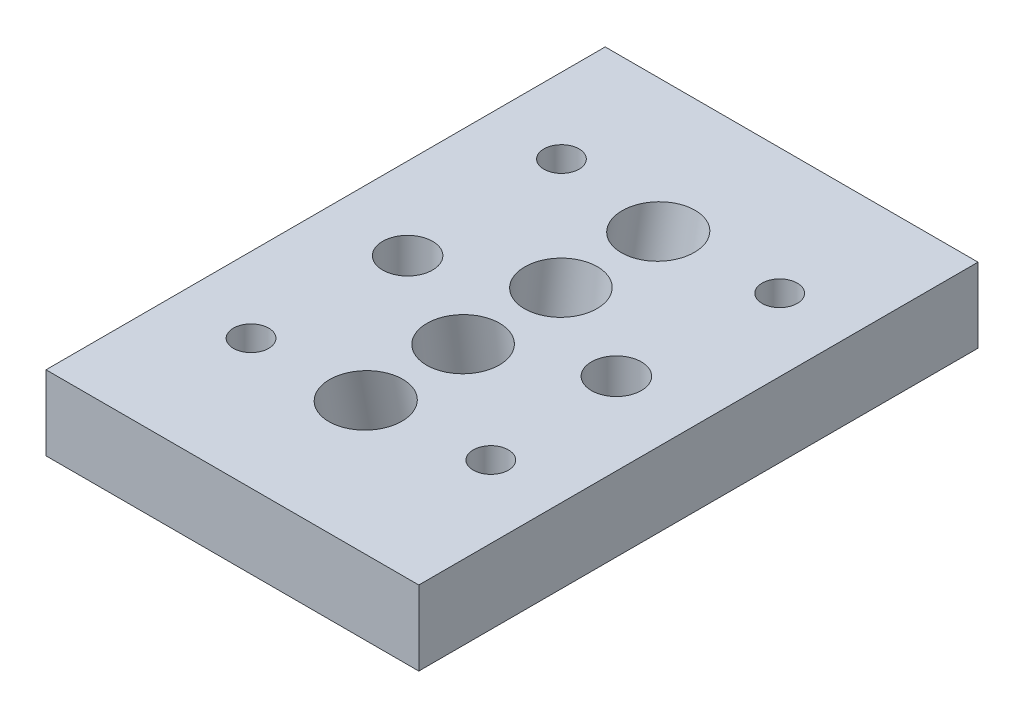
from build123d import *

# Parameters (mm, degrees)
SKETCH2_W                = 25.4
SKETCH2_H                = 38.1
BOSS_EXTRUDE1_DEPTH      = 5.08
CUT_EXTRUDE1_START       = -2.790735945
SKETCH7_R                = 2.4638
CUT_EXTRUDE1_DEPTH       = 11.685356434
CUT_EXTRUDE2_START       = -12.037410464
SKETCH16_R               = 2.4638
CUT_EXTRUDE2_DEPTH       = 14.163842911
M3_CLEARANCE_HOLE1_D     = 3.4
M3_CLEARANCE_HOLE1_DEPTH = 25.4
M3_CLEARANCE_HOLE1_TIP   = 1.021463052
M2_CLEARANCE_HOLE1_D     = 2.4
M2_CLEARANCE_HOLE1_DEPTH = 25.4
M2_CLEARANCE_HOLE1_TIP   = 0.721032743
M2_CLEARANCE_HOLE2_D     = 2.4
M2_CLEARANCE_HOLE2_DEPTH = 25.4
M2_CLEARANCE_HOLE2_TIP   = 0.721032743


with BuildPart() as part:
    # Sketch2 → Boss-Extrude1 (new body)
    with BuildSketch(Plane(origin=(0, 0, 0), x_dir=(1, 0, 0), z_dir=(0, 1, 0))):
        Rectangle(SKETCH2_W, SKETCH2_H)
    extrude(amount=BOSS_EXTRUDE1_DEPTH)

    # Sketch7 → Cut-Extrude1 (cut)
    with BuildSketch(Plane(origin=(12.7, 5.08, 4.3561), x_dir=(-1, 0, 0), z_dir=(0, -0.992546152, -0.121869343)).offset(CUT_EXTRUDE1_START)):
        with Locations((12.7, 1.016)):
            Circle(SKETCH7_R)
    cut_extrude1 = extrude(amount=CUT_EXTRUDE1_DEPTH, mode=Mode.SUBTRACT)

    # Sketch16 → Cut-Extrude2 (cut)
    with BuildSketch(Plane(origin=(12.7, 5.08, 13.0683), x_dir=(1, 0, 0), z_dir=(0, 0.982109046, 0.188313096)).offset(CUT_EXTRUDE2_START)):
        with Locations((-12.7, 3.048)):
            Circle(SKETCH16_R)
    cut_extrude2 = extrude(amount=CUT_EXTRUDE2_DEPTH, mode=Mode.SUBTRACT)

    # Mirror2: Cut-Extrude1, Cut-Extrude2 across plane
    add(cut_extrude1.mirror(Plane(origin=(0, 0, 0), x_dir=(1, 0, 0), z_dir=(0, 0, -1))), mode=Mode.SUBTRACT)
    add(cut_extrude2.mirror(Plane(origin=(0, 0, 0), x_dir=(1, 0, 0), z_dir=(0, 0, -1))), mode=Mode.SUBTRACT)

    # M3 Clearance Hole1
    with Locations(Plane(origin=(0, 5.08, 0), x_dir=(1, 0, 0), z_dir=(0, 1, 0))):
        with Locations((7.112, 0), (-7.112, 0)):
            Hole(M3_CLEARANCE_HOLE1_D / 2, depth=M3_CLEARANCE_HOLE1_DEPTH)
            with Locations((0, 0, -(M3_CLEARANCE_HOLE1_DEPTH + M3_CLEARANCE_HOLE1_TIP / 2))):  # 118° drill point
                Cone(0, M3_CLEARANCE_HOLE1_D / 2, M3_CLEARANCE_HOLE1_TIP, mode=Mode.SUBTRACT)

    # M2 Clearance Hole1
    with Locations(Plane(origin=(0, 5.08, 0), x_dir=(1, 0, 0), z_dir=(0, 1, 0))):
        with Locations((-7.573257477, -10.205203742), (-7.573257477, 10.942943937)):
            Hole(M2_CLEARANCE_HOLE1_D / 2, depth=M2_CLEARANCE_HOLE1_DEPTH)
            with Locations((0, 0, -(M2_CLEARANCE_HOLE1_DEPTH + M2_CLEARANCE_HOLE1_TIP / 2))):  # 118° drill point
                Cone(0, M2_CLEARANCE_HOLE1_D / 2, M2_CLEARANCE_HOLE1_TIP, mode=Mode.SUBTRACT)

    # M2 Clearance Hole2
    with Locations(Plane(origin=(0, 5.08, 0), x_dir=(1, 0, 0), z_dir=(0, 1, 0))):
        with Locations((7.779654049, -9.22186476), (7.779654049, 10.457647724)):
            Hole(M2_CLEARANCE_HOLE2_D / 2, depth=M2_CLEARANCE_HOLE2_DEPTH)
            with Locations((0, 0, -(M2_CLEARANCE_HOLE2_DEPTH + M2_CLEARANCE_HOLE2_TIP / 2))):  # 118° drill point
                Cone(0, M2_CLEARANCE_HOLE2_D / 2, M2_CLEARANCE_HOLE2_TIP, mode=Mode.SUBTRACT)


solid = part.part
